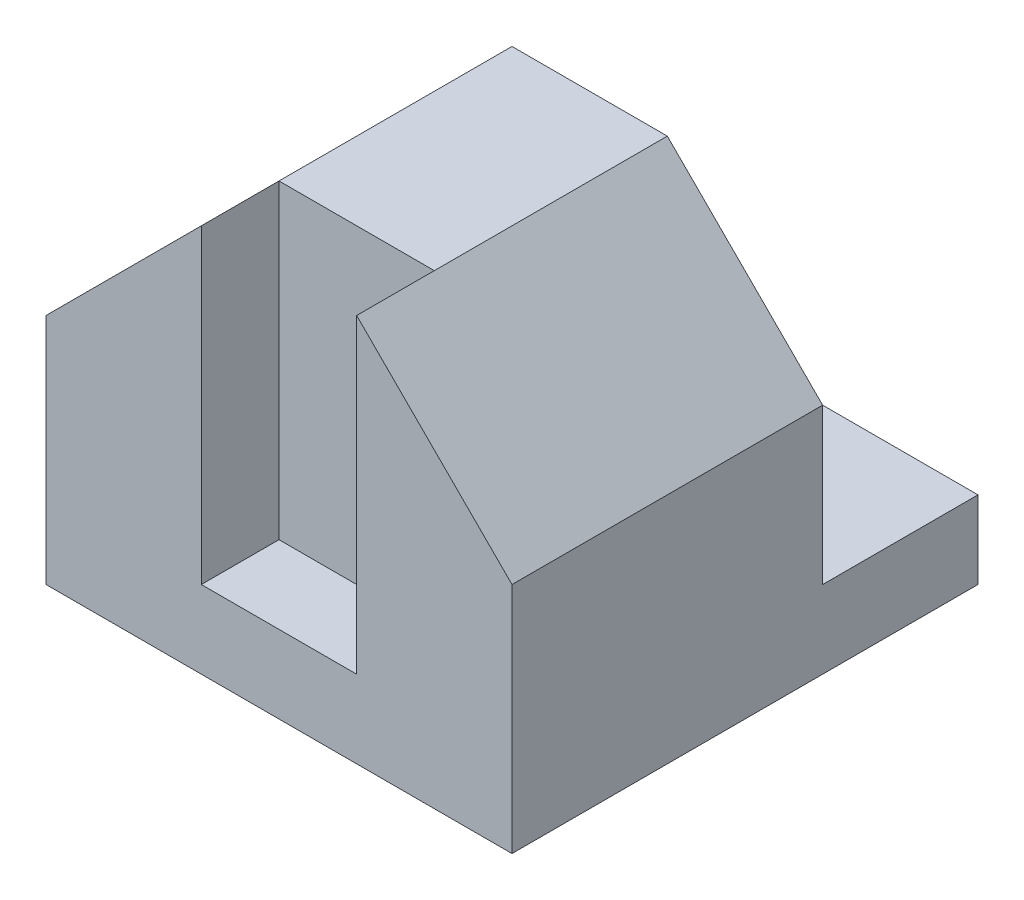
from build123d import *

# Parameters (mm, degrees)
SKETCH2_W           = 6
SKETCH2_H           = 6
BOSS_EXTRUDE1_DEPTH = 5
SKETCH3_W           = 2
SKETCH3_H           = 4
CUT_EXTRUDE1_DEPTH  = 8
CUT_EXTRUDE2_DEPTH  = 8
SKETCH5_W           = 2
SKETCH5_H           = 4
CUT_EXTRUDE3_DEPTH  = 1


with BuildPart() as part:
    # Sketch2 → Boss-Extrude1 (new body)
    with BuildSketch(Plane(origin=(0, 0, 0), x_dir=(1, 0, 0), z_dir=(0, 1, 0))):
        Rectangle(SKETCH2_W, SKETCH2_H)
    extrude(amount=BOSS_EXTRUDE1_DEPTH)

    # Sketch3 → Cut-Extrude1 (cut)
    with BuildSketch(Plane(origin=(3, 0, 0), x_dir=(0, 0, -1), z_dir=(1, 0, 0))):
        with Locations((2, 3)):
            Rectangle(SKETCH3_W, SKETCH3_H)
    extrude(amount=-CUT_EXTRUDE1_DEPTH, mode=Mode.SUBTRACT)

    # Sketch4 → Cut-Extrude2 (cut)
    with BuildSketch(Plane.XY.offset(3)):
        Polygon((-3, 3), (-1, 5), (-3, 5), align=None)
        Polygon((1, 5), (3, 5), (3, 3), align=None)
    extrude(amount=-CUT_EXTRUDE2_DEPTH, mode=Mode.SUBTRACT)

    # Sketch5 → Cut-Extrude3 (cut)
    with BuildSketch(Plane.XY.offset(3)):
        with Locations((0, 3)):
            Rectangle(SKETCH5_W, SKETCH5_H)
    extrude(amount=-CUT_EXTRUDE3_DEPTH, mode=Mode.SUBTRACT)


solid = part.part
